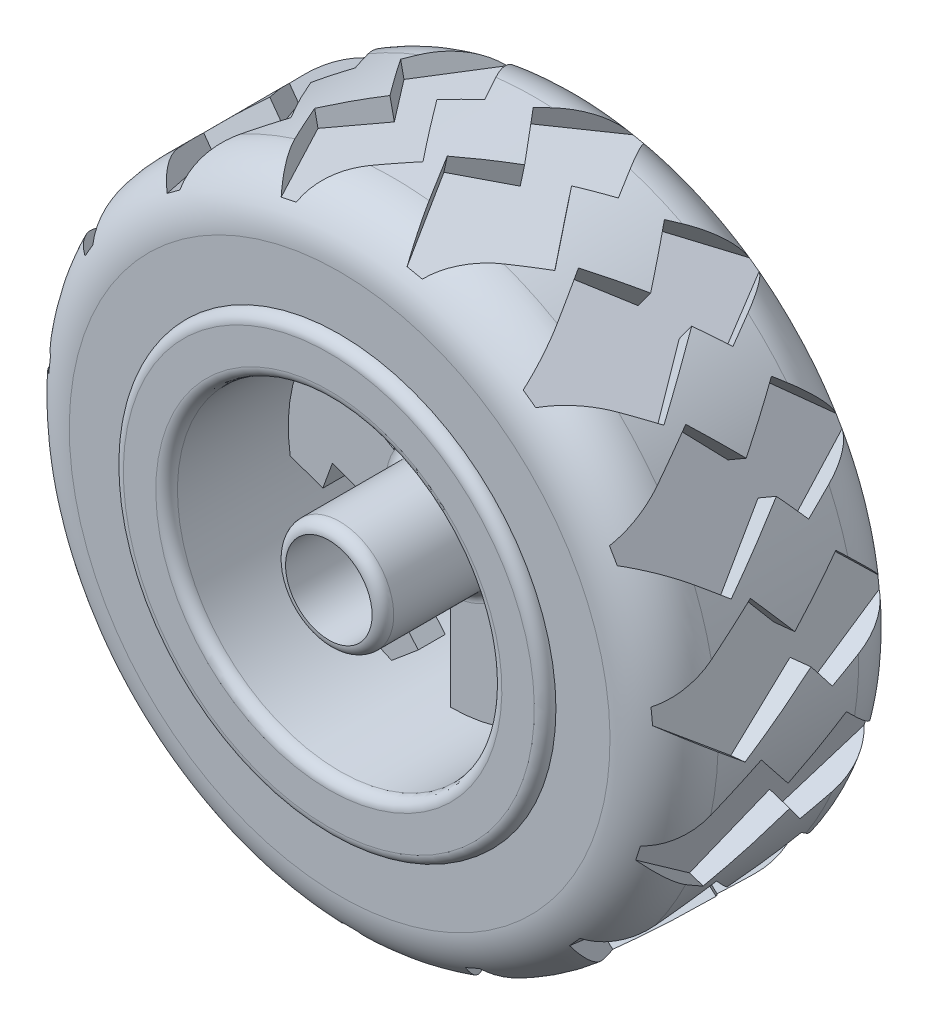
from build123d import *
from build123d.topology import SkipClean

# Parameters (mm, degrees)
CROQUIS2_R            = 4
CORTAR_EXTRUIR1_DEPTH = 38.749172296
CORTAR_EXTRUIR2_DEPTH = 32.449364127
CORTAR_EXTRUIR3_DEPTH = 2
MATRIZC1_COUNT        = 15


with BuildPart() as part:
    # Croquis1 → Revolución1 (revolve)
    with BuildSketch(Plane(origin=(0, 0, 0), x_dir=(0, 0, -1), z_dir=(1, 0, 0)), mode=Mode.PRIVATE) as revoluci_n1_sk:
        with BuildLine():
            Line((0, 0), (-11.5, 0))
            ThreePointArc((-11.5, 0), (-12.207106781, 0.292893219), (-12.5, 1))
            Line((-12.5, 1), (-12.5, 4))
            ThreePointArc((-12.5, 4), (-12.207106781, 4.707106781), (-11.5, 5))
            Line((-11.5, 5), (-2.25, 5))
            ThreePointArc((-2.25, 5), (-1.542893219, 5.292893219), (-1.25, 6))
            Line((-1.25, 6), (-1.25, 15))
            Line((-1.25, 15), (-11.5, 15))
            ThreePointArc((-11.5, 15), (-12.207106781, 15.292893219), (-12.5, 16))
            Line((-12.5, 16), (-12.5, 19))
            ThreePointArc((-12.5, 19), (-12.207106781, 19.707106781), (-11.5, 20))
            Line((-11.5, 20), (11.5, 20))
            ThreePointArc((11.5, 20), (12.207106781, 19.707106781), (12.5, 19))
            Line((12.5, 19), (12.5, 16))
            ThreePointArc((12.5, 16), (12.207106781, 15.292893219), (11.5, 15))
            Line((11.5, 15), (1.25, 15))
            Line((1.25, 15), (1.25, 6))
            ThreePointArc((1.25, 6), (1.542893219, 5.292893219), (2.25, 5))
            Line((2.25, 5), (11.5, 5))
            ThreePointArc((11.5, 5), (12.207106781, 4.707106781), (12.5, 4))
            Line((12.5, 4), (12.5, 1))
            ThreePointArc((12.5, 1), (12.207106781, 0.292893219), (11.5, 0))
            Line((11.5, 0), (0, 0))
        make_face()
    revolve(revoluci_n1_sk.sketch.rotate(Axis((0, 0, 0), (0, 0, -1)), 180), axis=Axis((0, 0, 0), (0, 0, -1)))

    # Croquis2 → Cortar-Extruir1 (cut, through all)
    with BuildSketch(Plane.XY.offset(12.5)):
        Circle(CROQUIS2_R)
    extrude(amount=-CORTAR_EXTRUIR1_DEPTH, mode=Mode.SUBTRACT)

    # Croquis3 → Cortar-Extruir2 (cut, through all)
    with SkipClean():  # the faces are left unmerged after this step: merging them gives an invalid solid
        with BuildSketch(Plane.XY.offset(1.25)):
            with BuildLine():
                Line((0, 15), (0, 6))
                Line((0, 6), (4.663844462, 9.913430168))
                Line((4.663844462, 9.913430168), (2.9856452, 11.913430168))
                Line((2.9856452, 11.913430168), (5.444807282, 13.976912165))
                ThreePointArc((5.444807282, 13.976912165), (2.770046708, 14.742009403), (0, 15))
            make_face()
            with BuildLine():
                Line((10.917204596, 0.9177073), (11.810155772, 3.371070494))
                Line((11.810155772, 3.371070494), (14.826764642, 2.273114657))
                ThreePointArc((14.826764642, 2.273114657), (14.151978, 4.972073882), (12.990381057, 7.5))
                Line((12.990381057, 7.5), (5.196152423, 3))
                Line((5.196152423, 3), (10.917204596, 0.9177073))
            make_face()
            with BuildLine():
                Line((6.253360133, -8.995722868), (8.824510572, -8.542359674))
                Line((8.824510572, -8.542359674), (9.38195736, -11.703797508))
                ThreePointArc((9.38195736, -11.703797508), (11.381931292, -9.76993552), (12.990381057, -7.5))
                Line((12.990381057, -7.5), (5.196152423, -3))
                Line((5.196152423, -3), (6.253360133, -8.995722868))
            make_face()
            with BuildLine():
                Line((-4.663844462, -9.913430168), (-2.9856452, -11.913430168))
                Line((-2.9856452, -11.913430168), (-5.444807282, -13.976912165))
                ThreePointArc((-5.444807282, -13.976912165), (-2.770046708, -14.742009403), (0, -15))
                Line((0, -15), (0, -6))
                Line((0, -6), (-4.663844462, -9.913430168))
            make_face()
            with BuildLine():
                Line((-10.917204596, -0.9177073), (-11.810155772, -3.371070494))
                Line((-11.810155772, -3.371070494), (-14.826764642, -2.273114657))
                ThreePointArc((-14.826764642, -2.273114657), (-14.151978, -4.972073882), (-12.990381057, -7.5))
                Line((-12.990381057, -7.5), (-5.196152423, -3))
                Line((-5.196152423, -3), (-10.917204596, -0.9177073))
            make_face()
            with BuildLine():
                Line((-6.253360133, 8.995722868), (-8.824510572, 8.542359674))
                Line((-8.824510572, 8.542359674), (-9.38195736, 11.703797508))
                ThreePointArc((-9.38195736, 11.703797508), (-11.381931292, 9.76993552), (-12.990381057, 7.5))
                Line((-12.990381057, 7.5), (-5.196152423, 3))
                Line((-5.196152423, 3), (-6.253360133, 8.995722868))
            make_face()
        extrude(amount=-CORTAR_EXTRUIR2_DEPTH, mode=Mode.SUBTRACT)

    # Croquis4 → Revolución2 (revolve)
    with SkipClean():  # the faces are left unmerged after this step: merging them gives an invalid solid
        with BuildSketch(Plane(origin=(0, 0, 0), x_dir=(0, 0, -1), z_dir=(1, 0, 0))):
            with BuildLine():
                Line((-11.5, 20), (11.5, 20))
                Line((11.5, 20), (11.5, 25))
                ThreePointArc((11.5, 25), (10.035533906, 28.535533906), (6.5, 30))
                Line((6.5, 30), (-6.5, 30))
                ThreePointArc((-6.5, 30), (-10.035533906, 28.535533906), (-11.5, 25))
                Line((-11.5, 25), (-11.5, 20))
            make_face()
        revolve(axis=Axis((0, 0, -12.5), (0, 0, 1)))

    # Croquis5 → Cortar-Extruir3 (cut)
    with SkipClean():  # the faces are left unmerged after this step: merging them gives an invalid solid
        with BuildSketch(Plane(origin=(0, -30, 0), x_dir=(-1, 0, 0), z_dir=(0, -1, 0))):
            Polygon((0, -11.5), (-5.540421075, -2.260846151), (-1.62936247, 0.969858613), (-5.466433849, 5.614978528), (0, 11.211565564), (4.112200518, 4.073406174), (1.623354319, 2.130508139), (6.284683811, -3.840640107), align=None)
        cortar_extruir3 = extrude(amount=-CORTAR_EXTRUIR3_DEPTH, mode=Mode.SUBTRACT)

    # MatrizC1: Cortar-Extruir3 ×15 about axis
    with SkipClean():  # the faces are left unmerged after this step: merging them gives an invalid solid
        matrizc1_axis = Axis((0, 0, 0), (0, 0, 1))
        for i in range(1, MATRIZC1_COUNT):
            add(cortar_extruir3.rotate(matrizc1_axis, i * 360 / MATRIZC1_COUNT), mode=Mode.SUBTRACT)


solid = part.part
